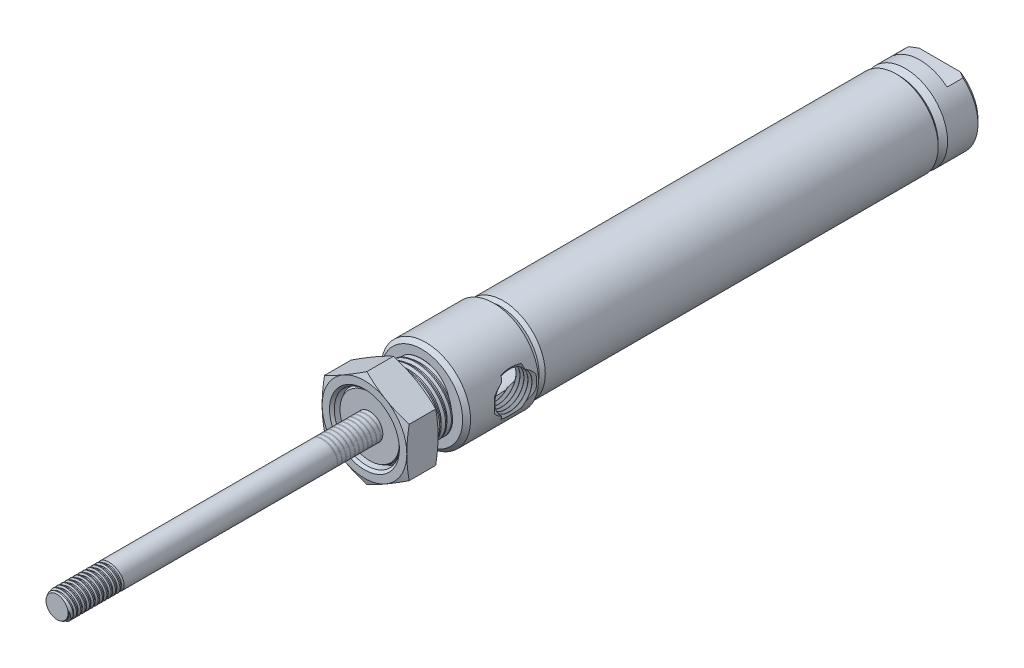
from build123d import *

# Parameters (mm, degrees)
SKETCH1_W               = 126.238
SKETCH1_H               = 10.287
CUT_EXTRUDE1_DEPTH      = 78.202108125
CUT_EXTRUDE1_DEPTH_BACK = 78.202108125
SKETCH2_W               = 4.826
SKETCH2_H               = 2.413
CHAMFER1_SIZE           = 0.9652
SKETCH4_W               = 12.7
SKETCH4_H               = 7.9375
LPATTERN2_COUNT         = 2
LPATTERN2_PITCH         = 1.411111111
LPATTERN2_COUNT_DIR2    = 9
LPATTERN2_PITCH_DIR2    = 1.411111111
LPATTERN3_COUNT         = 2
LPATTERN3_PITCH         = 1.058333333
LPATTERN3_COUNT_DIR2    = 12
LPATTERN3_PITCH_DIR2    = 1.058333333
LPATTERN4_COUNT         = 2
LPATTERN4_PITCH         = 63.5
SKETCH52_W              = 13.9192
SKETCH52_H              = 2.101274218
SKETCH54_R              = 7.9375
EXTRUDE1_DEPTH          = 7.62


with BuildPart() as part:
    # Sketch1 → Revolve1 (revolve)
    with BuildSketch(Plane(origin=(0, 0, 0), x_dir=(0, 0, -1), z_dir=(1, 0, 0))):
        with Locations((12.7, 5.1435)):
            Rectangle(SKETCH1_W, SKETCH1_H)
    revolve(axis=Axis((0, 0, -75.819), (0, 0, -1)))

    # Sketch2 → Cut-Extrude1 (cut, two sides: drawn at the far end of the back side and taken through both)
    with BuildSketch(Plane(origin=(0, 0, 0), x_dir=(0, 0, -1), z_dir=(1, 0, 0)).offset(-CUT_EXTRUDE1_DEPTH_BACK)):
        with Locations((73.406, 9.0805)):
            Rectangle(SKETCH2_W, SKETCH2_H)
        with Locations((73.406, -9.0805)):
            Rectangle(SKETCH2_W, SKETCH2_H)
    extrude(amount=CUT_EXTRUDE1_DEPTH + CUT_EXTRUDE1_DEPTH_BACK, mode=Mode.SUBTRACT)

    # Chamfer1
    chamfer1_edges = [part.edges().sort_by_distance(p)[0] for p in [
        (-10.287, 0, -75.819),
        (10.287, 0, -75.819),
        (0, -10.287, 50.419),
    ]]
    chamfer(chamfer1_edges, length=CHAMFER1_SIZE)


with BuildPart() as body_2:
    # Sketch4 → Revolve2 (revolve)
    with BuildSketch(Plane(origin=(0, 0, 0), x_dir=(0, 0, -1), z_dir=(1, 0, 0))):
        with Locations((-56.769, 3.96875)):
            Rectangle(SKETCH4_W, SKETCH4_H)
    revolve(axis=Axis((0, 0, 63.119), (0, 0, -1)))

    # Sketch5 → Cut-Revolve2 (revolve, cut)
    with BuildSketch(Plane(origin=(0, 0, 0), x_dir=(0, 0, -1), z_dir=(1, 0, 0))):
        Polygon((-62.943303854, 7.953117435), (-61.713430829, 8.062439482), (-62.085045717, 7.262609263), (-62.43643801, 7.231374393), align=None)
    cut_revolve2 = revolve(axis=Axis((0, -0.133549795, 63.119), (0, 0.08853979028379458, -0.9960726406926865)), mode=Mode.SUBTRACT)

    # Sketch6 → Cut-Revolve3 (revolve, cut)
    with BuildSketch(Plane(origin=(0, 0, 0), x_dir=(0, 0, -1), z_dir=(1, 0, 0))):
        Polygon((-63.119, 7.231374393), (-61.895954572, 7.9375), (-63.119, 7.9375), align=None)
    revolve(axis=Axis((0, 0, 0), (0, 0, 1)), mode=Mode.SUBTRACT)

    # LPattern2: Cut-Revolve2 2 × 9
    with Locations(*[Vector(0, 0, 1) * (i * LPATTERN2_PITCH) + Vector(0, 0, -1) * (j * LPATTERN2_PITCH_DIR2) for i in range(LPATTERN2_COUNT) for j in range(LPATTERN2_COUNT_DIR2) if (i, j) != (0, 0)]):
        add(cut_revolve2, mode=Mode.SUBTRACT)

    # Combine1: union part
    add(part.part)

    # Sketch7 → Cut-Revolve5 (revolve, cut)
    with BuildSketch(Plane(origin=(0, 0, 0), x_dir=(0, 0, -1), z_dir=(1, 0, 0))):
        Polygon((-63.119, 3.2004), (-44.069, 3.2004), (-44.069, 6.3627), (-17.907, 6.3627), (-17.907, 9.525), (-11.557, 9.525), (51.943, 9.525), (51.943, 0), (-63.119, 0), align=None)
    revolve(axis=Axis((0, 0, -51.943), (0, 0, -1)), mode=Mode.SUBTRACT)

    # Sketch3 → Cut-Revolve1 (revolve, cut)
    with BuildSketch(Plane(origin=(0, 0, 0), x_dir=(0, 0, -1), z_dir=(1, 0, 0))):
        Polygon((67.437, 10.287), (65.913, 8.763), (65.913, 9.525), (65.151, 10.287), align=None)
        Polygon((-31.369, 8.763), (-32.893, 10.287), (-30.607, 10.287), (-31.369, 9.525), align=None)
    revolve(axis=Axis((0, 0, -75.819), (0, 0, -1)), mode=Mode.SUBTRACT)

    # Sketch118 → Revolve4 (revolve)
    with BuildSketch(Plane(origin=(0, 0, 0), x_dir=(0, 0, -1), z_dir=(1, 0, 0))):
        Polygon((-49.4538, 10.287), (-50.419, 9.3218), (-50.419, 9.9568), (-49.4538, 10.922), (-32.893, 10.922), (-32.893, 10.287), align=None)
    revolve(axis=Axis((0, 0, 0), (0, 0, 1)))

    # Sketch13 → Cut-Revolve22 (revolve, cut)
    with BuildSketch(Plane(origin=(0, -1.751719437, 219.449698312), x_dir=(0, 0, -1), z_dir=(1, 0, 0))):
        Polygon((285.311898312, 1.751719437), (285.311898312, 5.954267873), (285.328851643, 5.985872456), (285.739637432, 6.751663753), (285.775484469, 6.752784028), (286.233286291, 6.014137451), (286.269133328, 6.015257727), (286.679919117, 6.781049024), (286.715766154, 6.7821693), (287.173567976, 6.043522722), (287.209415013, 6.044642998), (287.620200802, 6.810434295), (287.656047839, 6.811554571), (288.113849661, 6.072907993), (288.149696698, 6.074028269), (288.560482487, 6.839819566), (288.596329523, 6.840939842), (289.054131346, 6.102293264), (289.089978383, 6.10341354), (289.500764172, 6.869204837), (289.536611208, 6.870325113), (289.994413031, 6.131678535), (290.030260068, 6.132798811), (290.441045857, 6.898590108), (290.476892893, 6.899710384), (290.934694716, 6.161063807), (290.970541753, 6.162184082), (291.381327542, 6.927975379), (291.417174578, 6.929095655), (291.874976401, 6.190449078), (291.910823437, 6.191569354), (292.321609227, 6.95736065), (292.357456263, 6.958480926), (292.815258086, 6.219834349), (292.851105122, 6.220954625), (293.261890912, 6.986745921), (293.297737948, 6.987866197), (293.755539771, 6.24921962), (293.791386807, 6.250339896), (294.202172597, 7.016131192), (294.238019633, 7.017251468), (294.695821456, 6.278604891), (294.731668492, 6.279725167), (295.142454282, 7.045516464), (295.178301318, 7.046636739), (295.636103141, 6.307990162), (295.671950177, 6.309110438), (296.082735967, 7.074901735), (296.118583003, 7.076022011), (296.576384826, 6.337375433), (296.612231862, 6.338495709), (297.023017652, 7.104287006), (297.058864688, 7.105407282), (297.516666511, 6.366760704), (297.552513547, 6.36788098), (297.963299337, 7.133672277), (297.999146373, 7.134792553), (298.456948196, 6.396145975), (298.492795232, 6.397266251), (298.903581022, 7.163057548), (298.939428058, 7.164177824), (299.397229881, 6.425531246), (299.433076917, 6.426651522), (299.433076917, 1.751719437), align=None)
    revolve(axis=Axis((0, 0, -65.8622), (0, 0, 1)), mode=Mode.SUBTRACT)

    # Sketch52 → Cut-Revolve23 (revolve, cut)
    with BuildSketch(Plane(origin=(0, 0, 0), x_dir=(0, 0, -1), z_dir=(1, 0, 0))):
        with Locations((58.9026, 1.050637109)):
            Rectangle(SKETCH52_W, SKETCH52_H)
    revolve(axis=Axis((0, 0, -65.8622), (0, 0, 1)), mode=Mode.SUBTRACT)

    # Sketch116 → Cut-Revolve219 (revolve, cut)
    with BuildSketch(Plane(origin=(-125.566843264, -1.342253902, 38.481), x_dir=(1, 0, 0), z_dir=(0, 0, 1))):
        Polygon((126.532043264, 1.342253902), (126.532043264, 5.544802338), (126.548996595, 5.57640692), (126.959782384, 6.342198217), (126.995629421, 6.343318493), (127.453431243, 5.604671915), (127.48927828, 5.605792191), (127.900064069, 6.371583488), (127.935911106, 6.372703764), (128.393712928, 5.634057187), (128.429559965, 5.635177462), (128.840345754, 6.400968759), (128.876192791, 6.402089035), (129.333994613, 5.663442458), (129.36984165, 5.664562734), (129.780627439, 6.43035403), (129.816474476, 6.431474306), (130.274276298, 5.692827729), (130.310123335, 5.693948005), (130.720909124, 6.459739301), (130.756756161, 6.460859577), (131.214557983, 5.722213), (131.25040502, 5.723333276), (131.661190809, 6.489124572), (131.697037846, 6.490244848), (132.154839668, 5.751598271), (132.190686705, 5.752718547), (132.601472494, 6.518509844), (132.637319531, 6.519630119), (133.095121353, 5.780983542), (133.13096839, 5.782103818), (133.541754179, 6.547895115), (133.577601216, 6.549015391), (134.035403038, 5.810368813), (134.071250075, 5.811489089), (134.482035864, 6.577280386), (134.517882901, 6.578400662), (134.975684723, 5.839754084), (135.01153176, 5.84087436), (135.422317549, 6.606665657), (135.458164586, 6.607785933), (135.915966408, 5.869139355), (135.951813445, 5.870259631), (136.362599234, 6.636050928), (136.398446271, 6.637171204), (136.856248093, 5.898524626), (136.89209513, 5.899644902), (137.302880919, 6.665436199), (137.338727956, 6.666556475), (137.796529778, 5.927909898), (137.832376815, 5.929030173), (138.243162604, 6.69482147), (138.279009641, 6.695941746), (138.736811463, 5.957295169), (138.7726585, 5.958415445), (139.183444289, 6.724206741), (139.219291326, 6.725327017), (139.677093148, 5.98668044), (139.712940185, 5.987800716), (140.123725974, 6.753592012), (140.159573011, 6.754712288), (140.617374833, 6.016065711), (140.65322187, 6.017185987), (140.65322187, 1.342253902), align=None)
    revolve(axis=Axis((0.9652, 0, 38.481), (-1, 0, 0)), mode=Mode.SUBTRACT)


with BuildPart() as body_2_2:
    # Sketch8 → Revolve3 (revolve)
    with BuildSketch(Plane(origin=(0, 0, 0), x_dir=(0, 0, -1), z_dir=(1, 0, 0))):
        Polygon((39.243, 3.175), (39.243, 9.4742), (51.943, 9.4742), (51.943, 0), (-75.819, 0), (-75.819, 3.175), align=None)
    revolve(axis=Axis((0, 0, -51.943), (0, 0, 1)))

    # Sketch10 → Cut-Revolve6 (revolve, cut)
    with BuildSketch(Plane(origin=(0, 0, 0), x_dir=(0, 0, -1), z_dir=(1, 0, 0))):
        Polygon((-75.688508304, 3.196748616), (-74.775066431, 3.348988928), (-75.007121401, 2.729571769), (-75.268104794, 2.686074537), align=None)
    cut_revolve6 = revolve(axis=Axis((0, -0.188781794, 75.819), (0, 0.16439898730535646, -0.986393923832144)), mode=Mode.SUBTRACT)

    # Sketch11 → Cut-Revolve7 (revolve, cut)
    with BuildSketch(Plane(origin=(0, 0, 0), x_dir=(0, 0, -1), z_dir=(1, 0, 0))):
        Polygon((-75.819, 3.175), (-74.972156257, 3.175), (-75.819, 2.686074537), align=None)
    revolve(axis=Axis((0, 0, 0), (0, 0, 1)), mode=Mode.SUBTRACT)

    # LPattern3: Cut-Revolve6 2 × 12
    with Locations(*[Vector(0, 0, 1) * (i * LPATTERN3_PITCH) + Vector(0, 0, -1) * (j * LPATTERN3_PITCH_DIR2) for i in range(LPATTERN3_COUNT) for j in range(LPATTERN3_COUNT_DIR2) if (i, j) != (0, 0)]):
        add(cut_revolve6, mode=Mode.SUBTRACT)


with BuildPart() as lpattern4_1:
    # LPattern4: pattern copy
    add(body_2_2.part.moved(Location(Vector(0, 0, 1) * (1 * LPATTERN4_PITCH))))


with BuildPart() as body_4:
    # Sketch54 → Extrude1 (new body)
    with BuildSketch(Plane.XY.offset(56.769)):
        Polygon((0, 11.91506618), (-10.31875, 5.95753309), (-10.31875, -5.95753309), (0, -11.91506618), (10.31875, -5.95753309), (10.31875, 5.95753309), align=None)
        Circle(SKETCH54_R, mode=Mode.SUBTRACT)
    extrude(amount=EXTRUDE1_DEPTH)

    # Sketch55 → Cut-Revolve24 (revolve, cut)
    with BuildSketch(Plane(origin=(0, 0, 0), x_dir=(0, 0, -1), z_dir=(1, 0, 0))):
        Polygon((-63.807988426, 11.91506618), (-64.389, 11.91506618), (-64.389, 10.31875), align=None)
        Polygon((-57.350011574, 11.91506618), (-56.769, 11.91506618), (-56.769, 10.31875), align=None)
        Polygon((-64.389, 8.518511574), (-64.389, 7.9375), (-63.807988426, 7.9375), align=None)
        Polygon((-56.769, 8.518511574), (-56.769, 7.9375), (-57.350011574, 7.9375), align=None)
    revolve(axis=Axis((0, 0, 0), (0, 0, 1)), mode=Mode.SUBTRACT)


solid = Compound([body_2.part, body_2_2.part, lpattern4_1.part, body_4.part])
